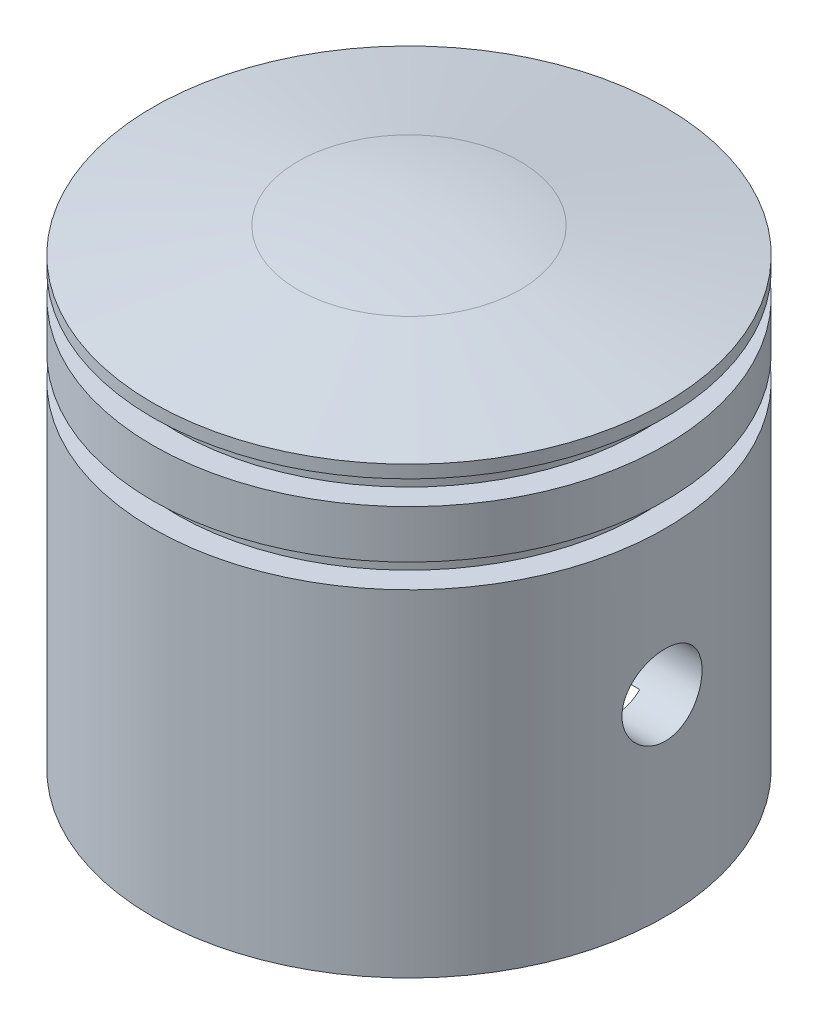
from build123d import *

# Parameters (mm, degrees)
SKETCH2_W               = 4.283382974
SKETCH2_H               = 1.5
SKETCH2_W_2             = 4.601745397
SKETCH3_R               = 10
CUT_EXTRUDE1_DEPTH      = 24
SKETCH4_R               = 13
CUT_EXTRUDE2_DEPTH      = 10
SKETCH5_R               = 2.5
CUT_EXTRUDE3_DEPTH      = 17
CUT_EXTRUDE3_DEPTH_BACK = 17


with BuildPart() as part:
    # Sketch1 → Revolve1 (revolve)
    with BuildSketch(Plane.XY):
        with BuildLine():
            Line((0, 0), (16, 0))
            Line((16, 0), (16, 27.795832784))
            Line((16, 27.795832784), (6.945927107, 29.39231012))
            ThreePointArc((6.945927107, 29.39231012), (3.48622971, 29.847787924), (0, 30))
            Line((0, 30), (0, 0))
        make_face()
    revolve(axis=Axis((0, 30, 0), (0, -1, 0)))

    # Sketch2 → Cut-Revolve1 (revolve, cut)
    with BuildSketch(Plane.XY):
        with Locations((16.641691487, 26.25)):
            Rectangle(SKETCH2_W, SKETCH2_H)
        with Locations((16.800872699, 21.75)):
            Rectangle(SKETCH2_W_2, SKETCH2_H)
    revolve(axis=Axis((0, 0, 0), (0, 1, 0)), mode=Mode.SUBTRACT)

    # Sketch3 → Cut-Extrude1 (cut)
    with BuildSketch(Plane.XZ):
        Circle(SKETCH3_R)
    extrude(amount=-CUT_EXTRUDE1_DEPTH, mode=Mode.SUBTRACT)

    # Sketch4 → Cut-Extrude2 (cut)
    with BuildSketch(Plane.XZ):
        Circle(SKETCH4_R)
    extrude(amount=-CUT_EXTRUDE2_DEPTH, mode=Mode.SUBTRACT)

    # Sketch5 → Cut-Extrude3 (cut, two sides)
    with BuildSketch(Plane(origin=(0, 0, 0), x_dir=(0, 0, -1), z_dir=(1, 0, 0))) as cut_extrude3_sk:
        with Locations((0, 12)):
            Circle(SKETCH5_R)
    extrude(amount=CUT_EXTRUDE3_DEPTH, mode=Mode.SUBTRACT)
    extrude(cut_extrude3_sk.sketch, amount=-CUT_EXTRUDE3_DEPTH_BACK, mode=Mode.SUBTRACT)


solid = part.part
